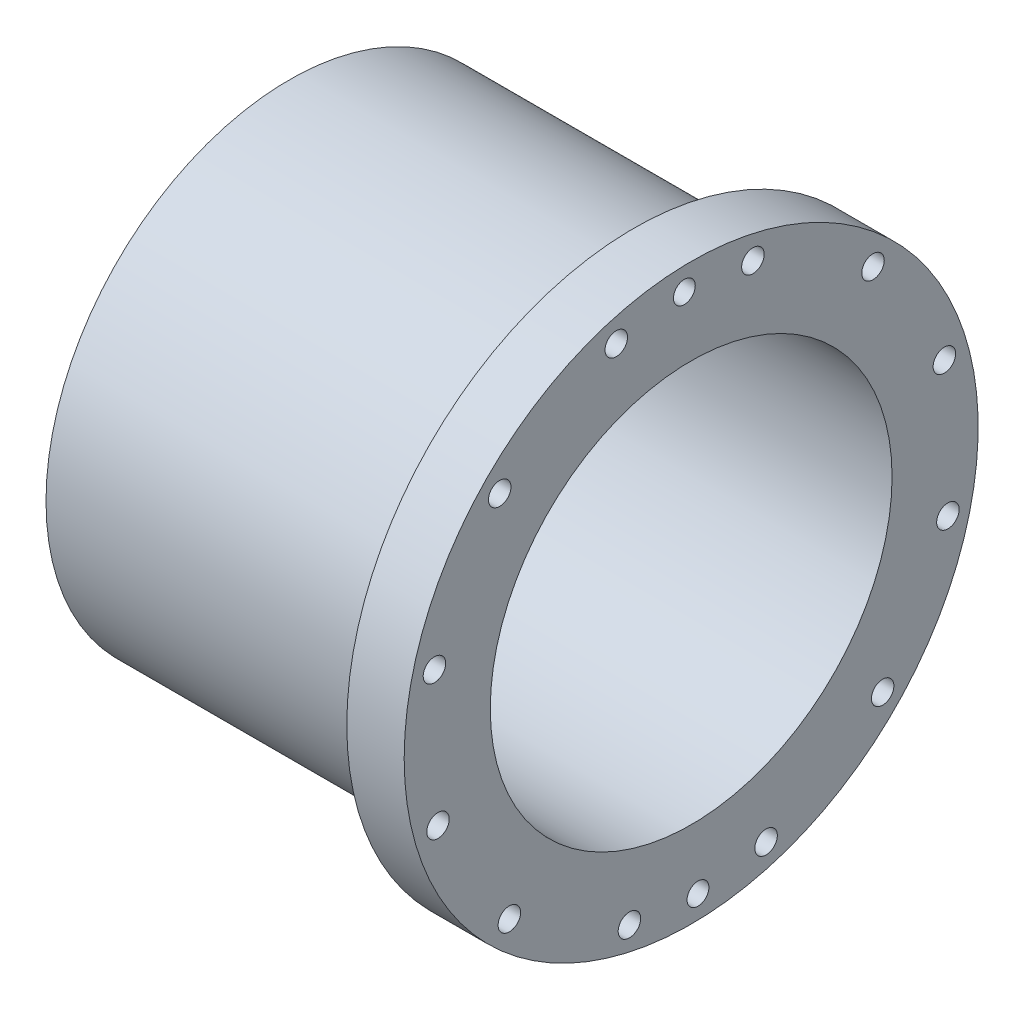
from build123d import *

# Parameters (mm, degrees)
SKETCH7_R                       = 2.4892
CUT_EXTRUDE1_DEPTH              = 127.363404513
F_21_0_159_DIAMETER_HOLE1_D     = 4.0386
F_21_0_159_DIAMETER_HOLE1_DEPTH = 17.78
F_21_0_159_DIAMETER_HOLE1_TIP   = 1.213317848
SKETCH15_R                      = 2.413
CUT_EXTRUDE2_DEPTH              = 4.826


with BuildPart() as part:
    # Sketch1 → Revolve1 (revolve)
    with BuildSketch(Plane.XY):
        Polygon((-88.9, 53.848), (-88.9, 44.45), (0, 44.45), (0, 63.5), (-12.7, 63.5), (-12.7, 53.848), align=None)
    revolve(axis=Axis((-87.283636364, 0, 0), (1, 0, 0)))

    # Sketch7 → Cut-Extrude1 (cut, through all)
    with BuildSketch(Plane(origin=(0, 0, 0), x_dir=(0, 0, -1), z_dir=(1, 0, 0))):
        with Locations((-16.571472984, 56.020377392)):
            Circle(SKETCH7_R)
        with Locations((13.658872113, 56.800806443)):
            Circle(SKETCH7_R)
        with Locations((40.229333459, 42.361505278)):
            Circle(SKETCH7_R)
        with Locations((56.020377392, 16.571472984)):
            Circle(SKETCH7_R)
        with Locations((56.800806443, -13.658872113)):
            Circle(SKETCH7_R)
        with Locations((42.361505278, -40.229333459)):
            Circle(SKETCH7_R)
        with Locations((16.571472984, -56.020377392)):
            Circle(SKETCH7_R)
        with Locations((-13.658872113, -56.800806443)):
            Circle(SKETCH7_R)
        with Locations((-40.229333459, -42.361505278)):
            Circle(SKETCH7_R)
        with Locations((-56.020377392, -16.571472984)):
            Circle(SKETCH7_R)
        with Locations((-56.800806443, 13.658872113)):
            Circle(SKETCH7_R)
        with Locations((-42.361505278, 40.229333459)):
            Circle(SKETCH7_R)
    extrude(amount=-CUT_EXTRUDE1_DEPTH, mode=Mode.SUBTRACT)

    # 21 _0.159_ Diameter Hole1
    with Locations(Plane.ZY.offset(88.9)):
        with Locations((-33.845113149, 35.638918571), (1.268411978, 49.132630014), (35.638918571, 33.845113149), (49.132630014, -1.268411978), (33.845113149, -35.638918571), (-1.268411978, -49.132630014), (-35.638918571, -33.845113149), (-49.132630014, 1.268411978)):
            Hole(F_21_0_159_DIAMETER_HOLE1_D / 2, depth=F_21_0_159_DIAMETER_HOLE1_DEPTH)
            with Locations((0, 0, -(F_21_0_159_DIAMETER_HOLE1_DEPTH + F_21_0_159_DIAMETER_HOLE1_TIP / 2))):  # 118° drill point
                Cone(0, F_21_0_159_DIAMETER_HOLE1_D / 2, F_21_0_159_DIAMETER_HOLE1_TIP, mode=Mode.SUBTRACT)

    # Sketch15 → Cut-Extrude2 (cut)
    with BuildSketch(Plane(origin=(0, 0, 0), x_dir=(0, 0, -1), z_dir=(1, 0, 0))):
        with Locations((-1.507673152, 58.400542135)):
            Circle(SKETCH15_R)
        with Locations((1.507673152, -58.400542135)):
            Circle(SKETCH15_R)
    extrude(amount=-CUT_EXTRUDE2_DEPTH, mode=Mode.SUBTRACT)


solid = part.part
